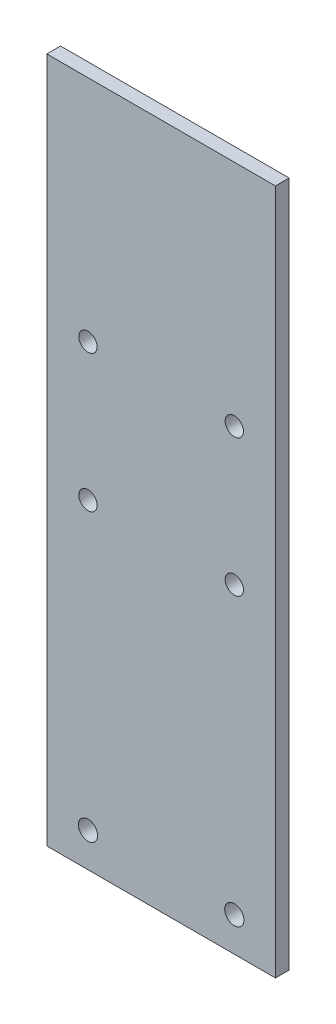
from build123d import *

# Parameters (mm, degrees)
SKETCH1_W           = 50
SKETCH1_H           = 150
BOSS_EXTRUDE1_DEPTH = 3
SKETCH2_R           = 2
CUT_EXTRUDE2_DEPTH  = 153.098652197
SKETCH3_R           = 2.1
CUT_EXTRUDE4_DEPTH  = 153.098652197


with BuildPart() as part:
    # Sketch1 → Boss-Extrude1 (new body)
    with BuildSketch(Plane.XY):
        with Locations((0, -75)):
            Rectangle(SKETCH1_W, SKETCH1_H)
    extrude(amount=BOSS_EXTRUDE1_DEPTH)

    # Sketch2 → Cut-Extrude2 (cut, through all)
    with BuildSketch(Plane.XY):
        with Locations((-16, -50)):
            Circle(SKETCH2_R)
        with Locations((16, -50)):
            Circle(SKETCH2_R)
        with Locations((-16, -80)):
            Circle(SKETCH2_R)
        with Locations((16, -80)):
            Circle(SKETCH2_R)
    extrude(amount=CUT_EXTRUDE2_DEPTH, mode=Mode.SUBTRACT)

    # Sketch3 → Cut-Extrude4 (cut, through all)
    with BuildSketch(Plane.XY):
        with Locations((-16, -142.5)):
            Circle(SKETCH3_R)
        with Locations((16, -142.5)):
            Circle(SKETCH3_R)
    extrude(amount=CUT_EXTRUDE4_DEPTH, mode=Mode.SUBTRACT)


solid = part.part
